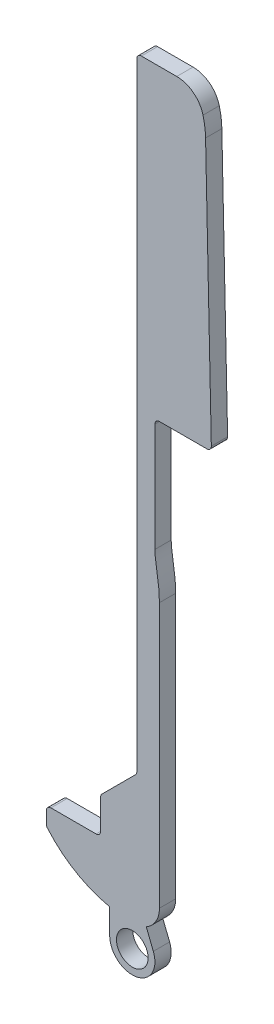
from build123d import *

# Parameters (mm, degrees)
BOSS_EXTRUDE1_DEPTH = 1.8
FILLET1_R           = 0.5
SKETCH2_R           = 1.75
BOSS_EXTRUDE3_DEPTH = 1.8
FILLET2_R           = 3


with BuildPart() as part:
    # Sketch1 → Boss-Extrude1 (new body)
    with BuildSketch(Plane.XY):
        with BuildLine():
            Line((0, 4.5), (0, 6.5))
            Line((0, 6.5), (6, 6.5))
            Line((6, 6.5), (6, 10.5))
            Line((6, 10.5), (10, 14.5))
            Line((10, 14.5), (10, 83.5))
            Line((10, 83.5), (16.4, 83.5))
            ThreePointArc((16.4, 83.5), (17.2719581, 81.425344658), (17.601960582, 79.199226044))
            Line((17.601960582, 79.199226044), (18.25, 49.5))
            Line((18.25, 49.5), (12, 49.5))
            Line((12, 49.5), (12, 37))
            add(Edge.make_bspline(
                [(12, 37), (12, 35.742192932), (12.5, 34.153450807), (12.5, 32.15)],
                knots=[0, 0, 0, 0, 1, 1, 1, 1], degree=3))
            Line((12.5, 32.15), (12.5, 2.89))
            ThreePointArc((12.5, 2.89), (11.653538598, 0.846461402), (9.61, 0))
            ThreePointArc((9.61, 0), (4.304293167, 1.180712741), (0, 4.5))
        make_face()
    extrude(amount=BOSS_EXTRUDE1_DEPTH)

    # Fillet1
    fillet1_edges = [part.edges().sort_by_distance(p)[0] for p in [
        (0, 4.5, 0.9),
        (0, 6.5, 0.9),
        (6, 6.5, 0.9),
        (6, 10.5, 0.9),
        (10, 14.5, 0.9),
        (10, 83.5, 0.9),
        (18.25, 49.5, 0.9),
        (12, 49.5, 0.9),
    ]]
    fillet(fillet1_edges, radius=FILLET1_R)

    # Sketch2 → Boss-Extrude3 (add)
    with BuildSketch(Plane.XY):
        with BuildLine():
            Line((7, -2.499596966), (7, 0.500403034))
            Line((7, 0.500403034), (11, 0.500403034))
            Line((11, 0.500403034), (11.824045318, -1.578286292))
            ThreePointArc((11.824045318, -1.578286292), (9.968981185, -4.955214332), (7, -2.499596966))
        make_face()
        with Locations((9.5, -2.499596966)):
            Circle(SKETCH2_R, mode=Mode.SUBTRACT)
    extrude(amount=BOSS_EXTRUDE3_DEPTH)

    # Fillet2
    fillet2_edges = [part.edges().sort_by_distance(p)[0] for p in [
        (16.4, 83.5, 0.9),
    ]]
    fillet(fillet2_edges, radius=FILLET2_R)


solid = part.part
